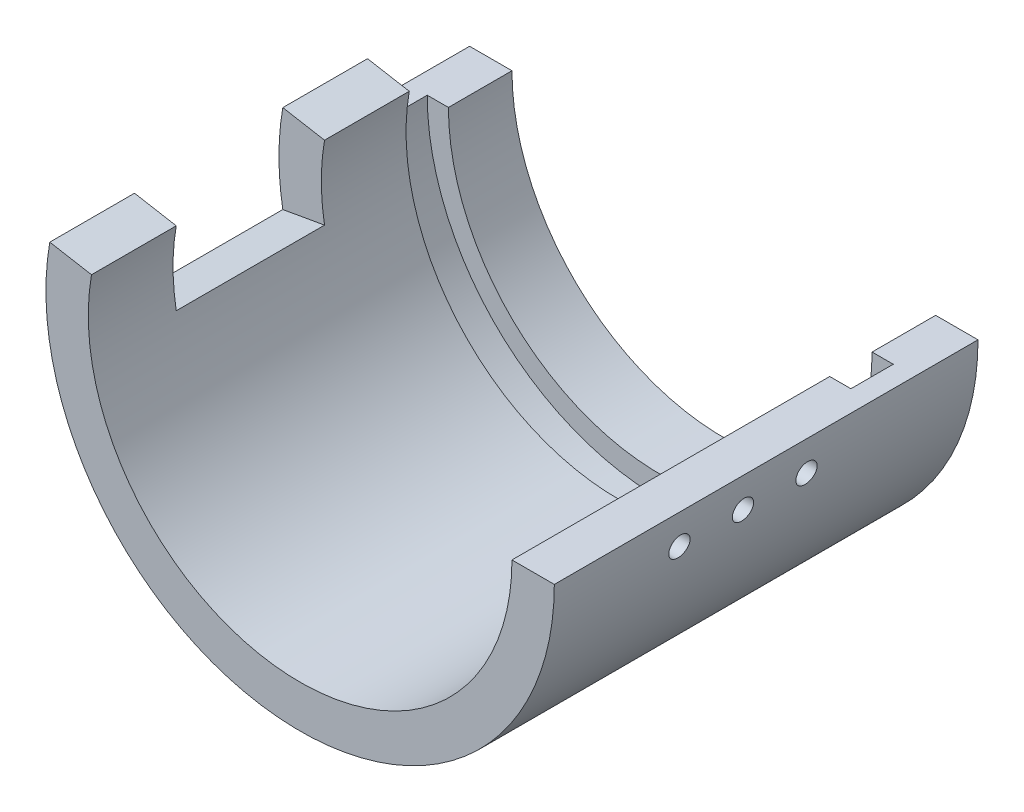
from build123d import *

# Parameters (mm, degrees)
REVOLVE1_ANGLE     = 180
SKETCH2_W          = 10
SKETCH2_H          = 35
CUT_REVOLVE1_ANGLE = 10
SKETCH4_R          = 2.5
CUT_EXTRUDE1_DEPTH = 20
SKETCH5_W          = 10
SKETCH5_H          = 20
REVOLVE2_ANGLE     = 10


with BuildPart() as part:
    # Sketch1 → Revolve1 (revolve)
    with BuildSketch(Plane(origin=(0, 0, 0), x_dir=(1, 0, 0), z_dir=(0, 1, 0))):
        Polygon((-60, 19.117647059), (-60, -80.882352941), (-50, -80.882352941), (-50, -5.882352941), (-55, -5.882352941), (-55, 4.117647059), (-50, 4.117647059), (-50, 19.117647059), align=None)
    revolve(axis=Axis((0, 0, -69.117647059), (0, 0, 1)), revolution_arc=REVOLVE1_ANGLE)

    # Sketch2 → Cut-Revolve1 (revolve, cut)
    with BuildSketch(Plane(origin=(0, 0, 0), x_dir=(1, 0, 0), z_dir=(0, 1, 0))):
        with Locations((-55, -43.382352941)):
            Rectangle(SKETCH2_W, SKETCH2_H)
    revolve(axis=Axis((0, 0, 80.882352941), (0, 0, 1)), revolution_arc=CUT_REVOLVE1_ANGLE, mode=Mode.SUBTRACT)

    # Sketch4 → Cut-Extrude1 (cut)
    with BuildSketch(Plane(origin=(60, 0, 0), x_dir=(0, 0, 1), z_dir=(1, 0, 0))):
        with Locations((35.882352941, 7.5)):
            Circle(SKETCH4_R)
        with Locations((50.882352941, 7.5)):
            Circle(SKETCH4_R)
        with Locations((20.882352941, 7.5)):
            Circle(SKETCH4_R)
    extrude(amount=-CUT_EXTRUDE1_DEPTH, mode=Mode.SUBTRACT)

    # Sketch5 → Revolve2 (revolve)
    with BuildSketch(Plane(origin=(0, 0, 0), x_dir=(1, 0, 0), z_dir=(0, 1, 0))):
        with Locations((-55, -70.882352941)):
            Rectangle(SKETCH5_W, SKETCH5_H)
        with Locations((-55, -15.882352941)):
            Rectangle(SKETCH5_W, SKETCH5_H)
    revolve(axis=Axis((0, 0, 85.860952493), (0, 0, -1)), revolution_arc=REVOLVE2_ANGLE)


solid = part.part
